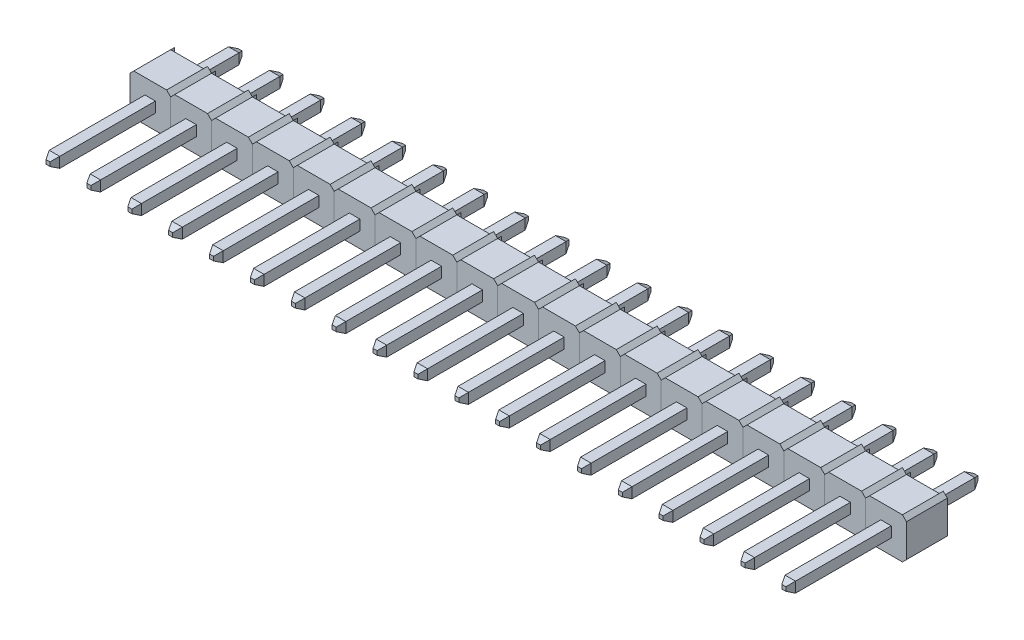
from build123d import *

# Parameters (mm, degrees)
SKETCH_14119_W             = 0.65
SKETCH_14119_H             = 0.65
EXTRUDE_14471_DEPTH        = 2.29
EXTRUDE_14851_DEPTH        = 0.25
SKETCH_14911_W             = 0.65
SKETCH_14911_H             = 0.65
EXTRUDE_15123_DEPTH        = 6.35
EXTRUDE_15123_DEPTH_BACK   = 5.59
CHAMFER_15214_SIZE         = 0.2
CHAMFER_15214_SIZE2        = 0.4
CHAMFER_15307_SIZE         = 0.2
CHAMFER_15307_SIZE2        = 0.4
PATTERN_LINEAR_15391_COUNT = 19
PATTERN_LINEAR_15391_PITCH = 2.54


with BuildPart() as part:
    # Sketch 14119 → Extrude 14471 (new body)
    with BuildSketch(Plane.XY):
        Polygon((1.02, 1.27), (1.27, 1.02), (1.27, -1.02), (1.02, -1.27), (-1.02, -1.27), (-1.27, -1.02), (-1.27, 1.02), (-1.02, 1.27), align=None)
        Rectangle(SKETCH_14119_W, SKETCH_14119_H, mode=Mode.SUBTRACT)
    extrude(amount=EXTRUDE_14471_DEPTH)

    # Sketch 14516 → Extrude 14851 (add)
    with BuildSketch(Plane(origin=(0, 0, 0), x_dir=(-1, 0, 0), z_dir=(0, 0, -1))):
        Polygon((-1.02, 1.27), (-1.27, 1.02), (-1.27, -1.02), (-1.02, -1.27), align=None)
        Polygon((1.02, 1.27), (1.27, 1.02), (1.27, -1.02), (1.02, -1.27), align=None)
    extrude(amount=EXTRUDE_14851_DEPTH)


with BuildPart() as body_2:
    # Sketch 14911 → Extrude 15123 (new body, two sides)
    with BuildSketch(Plane.XY.offset(2.29)) as extrude_15123_sk:
        Rectangle(SKETCH_14911_W, SKETCH_14911_H)
    extrude(amount=EXTRUDE_15123_DEPTH)
    extrude(extrude_15123_sk.sketch, amount=-EXTRUDE_15123_DEPTH_BACK)

    # Chamfer 15214
    chamfer_15214_edges = [body_2.edges().sort_by_distance(p)[0] for p in [
        (-0.325, 0, 8.64),
        (0, -0.325, 8.64),
        (0.325, 0, 8.64),
        (0, 0.325, 8.64),
    ]]
    chamfer_15214_side = [body_2.faces().sort_by_distance(p)[0] for p in [
        (0, 0, 8.64),
    ]]
    chamfer(chamfer_15214_edges, length=CHAMFER_15214_SIZE, length2=CHAMFER_15214_SIZE2, reference=chamfer_15214_side[0])

    # Chamfer 15307
    chamfer_15307_edges = [body_2.edges().sort_by_distance(p)[0] for p in [
        (0, -0.325, -3.3),
        (0.325, 0, -3.3),
        (0, 0.325, -3.3),
        (-0.325, 0, -3.3),
    ]]
    chamfer_15307_side = [body_2.faces().sort_by_distance(p)[0] for p in [
        (0, 0, -3.3),
    ]]
    chamfer(chamfer_15307_edges, length=CHAMFER_15307_SIZE, length2=CHAMFER_15307_SIZE2, reference=chamfer_15307_side[0])


with BuildPart() as pattern_linear_15391_1:
    # Pattern Linear 15391: pattern copy
    add(body_2.part.moved(Location(Vector(-1, 0, 0) * (1 * PATTERN_LINEAR_15391_PITCH))))


with BuildPart() as pattern_linear_15391_2:
    # Pattern Linear 15391: pattern copy
    add(body_2.part.moved(Location(Vector(-1, 0, 0) * (2 * PATTERN_LINEAR_15391_PITCH))))


with BuildPart() as pattern_linear_15391_3:
    # Pattern Linear 15391: pattern copy
    add(body_2.part.moved(Location(Vector(-1, 0, 0) * (3 * PATTERN_LINEAR_15391_PITCH))))


with BuildPart() as pattern_linear_15391_4:
    # Pattern Linear 15391: pattern copy
    add(body_2.part.moved(Location(Vector(-1, 0, 0) * (4 * PATTERN_LINEAR_15391_PITCH))))


with BuildPart() as pattern_linear_15391_5:
    # Pattern Linear 15391: pattern copy
    add(body_2.part.moved(Location(Vector(-1, 0, 0) * (5 * PATTERN_LINEAR_15391_PITCH))))


with BuildPart() as pattern_linear_15391_6:
    # Pattern Linear 15391: pattern copy
    add(body_2.part.moved(Location(Vector(-1, 0, 0) * (6 * PATTERN_LINEAR_15391_PITCH))))


with BuildPart() as pattern_linear_15391_7:
    # Pattern Linear 15391: pattern copy
    add(body_2.part.moved(Location(Vector(-1, 0, 0) * (7 * PATTERN_LINEAR_15391_PITCH))))


with BuildPart() as pattern_linear_15391_8:
    # Pattern Linear 15391: pattern copy
    add(body_2.part.moved(Location(Vector(-1, 0, 0) * (8 * PATTERN_LINEAR_15391_PITCH))))


with BuildPart() as pattern_linear_15391_9:
    # Pattern Linear 15391: pattern copy
    add(body_2.part.moved(Location(Vector(-1, 0, 0) * (9 * PATTERN_LINEAR_15391_PITCH))))


with BuildPart() as pattern_linear_15391_10:
    # Pattern Linear 15391: pattern copy
    add(body_2.part.moved(Location(Vector(-1, 0, 0) * (10 * PATTERN_LINEAR_15391_PITCH))))


with BuildPart() as pattern_linear_15391_11:
    # Pattern Linear 15391: pattern copy
    add(body_2.part.moved(Location(Vector(-1, 0, 0) * (11 * PATTERN_LINEAR_15391_PITCH))))


with BuildPart() as pattern_linear_15391_12:
    # Pattern Linear 15391: pattern copy
    add(body_2.part.moved(Location(Vector(-1, 0, 0) * (12 * PATTERN_LINEAR_15391_PITCH))))


with BuildPart() as pattern_linear_15391_13:
    # Pattern Linear 15391: pattern copy
    add(body_2.part.moved(Location(Vector(-1, 0, 0) * (13 * PATTERN_LINEAR_15391_PITCH))))


with BuildPart() as pattern_linear_15391_14:
    # Pattern Linear 15391: pattern copy
    add(body_2.part.moved(Location(Vector(-1, 0, 0) * (14 * PATTERN_LINEAR_15391_PITCH))))


with BuildPart() as pattern_linear_15391_15:
    # Pattern Linear 15391: pattern copy
    add(body_2.part.moved(Location(Vector(-1, 0, 0) * (15 * PATTERN_LINEAR_15391_PITCH))))


with BuildPart() as pattern_linear_15391_16:
    # Pattern Linear 15391: pattern copy
    add(body_2.part.moved(Location(Vector(-1, 0, 0) * (16 * PATTERN_LINEAR_15391_PITCH))))


with BuildPart() as pattern_linear_15391_17:
    # Pattern Linear 15391: pattern copy
    add(body_2.part.moved(Location(Vector(-1, 0, 0) * (17 * PATTERN_LINEAR_15391_PITCH))))


with BuildPart() as pattern_linear_15391_18:
    # Pattern Linear 15391: pattern copy
    add(body_2.part.moved(Location(Vector(-1, 0, 0) * (18 * PATTERN_LINEAR_15391_PITCH))))


with BuildPart() as pattern_linear_15391_19:
    # Pattern Linear 15391: pattern copy
    add(part.part.moved(Location(Vector(-1, 0, 0) * (1 * PATTERN_LINEAR_15391_PITCH))))


with BuildPart() as pattern_linear_15391_20:
    # Pattern Linear 15391: pattern copy
    add(part.part.moved(Location(Vector(-1, 0, 0) * (2 * PATTERN_LINEAR_15391_PITCH))))


with BuildPart() as pattern_linear_15391_21:
    # Pattern Linear 15391: pattern copy
    add(part.part.moved(Location(Vector(-1, 0, 0) * (3 * PATTERN_LINEAR_15391_PITCH))))


with BuildPart() as pattern_linear_15391_22:
    # Pattern Linear 15391: pattern copy
    add(part.part.moved(Location(Vector(-1, 0, 0) * (4 * PATTERN_LINEAR_15391_PITCH))))


with BuildPart() as pattern_linear_15391_23:
    # Pattern Linear 15391: pattern copy
    add(part.part.moved(Location(Vector(-1, 0, 0) * (5 * PATTERN_LINEAR_15391_PITCH))))


with BuildPart() as pattern_linear_15391_24:
    # Pattern Linear 15391: pattern copy
    add(part.part.moved(Location(Vector(-1, 0, 0) * (6 * PATTERN_LINEAR_15391_PITCH))))


with BuildPart() as pattern_linear_15391_25:
    # Pattern Linear 15391: pattern copy
    add(part.part.moved(Location(Vector(-1, 0, 0) * (7 * PATTERN_LINEAR_15391_PITCH))))


with BuildPart() as pattern_linear_15391_26:
    # Pattern Linear 15391: pattern copy
    add(part.part.moved(Location(Vector(-1, 0, 0) * (8 * PATTERN_LINEAR_15391_PITCH))))


with BuildPart() as pattern_linear_15391_27:
    # Pattern Linear 15391: pattern copy
    add(part.part.moved(Location(Vector(-1, 0, 0) * (9 * PATTERN_LINEAR_15391_PITCH))))


with BuildPart() as pattern_linear_15391_28:
    # Pattern Linear 15391: pattern copy
    add(part.part.moved(Location(Vector(-1, 0, 0) * (10 * PATTERN_LINEAR_15391_PITCH))))


with BuildPart() as pattern_linear_15391_29:
    # Pattern Linear 15391: pattern copy
    add(part.part.moved(Location(Vector(-1, 0, 0) * (11 * PATTERN_LINEAR_15391_PITCH))))


with BuildPart() as pattern_linear_15391_30:
    # Pattern Linear 15391: pattern copy
    add(part.part.moved(Location(Vector(-1, 0, 0) * (12 * PATTERN_LINEAR_15391_PITCH))))


with BuildPart() as pattern_linear_15391_31:
    # Pattern Linear 15391: pattern copy
    add(part.part.moved(Location(Vector(-1, 0, 0) * (13 * PATTERN_LINEAR_15391_PITCH))))


with BuildPart() as pattern_linear_15391_32:
    # Pattern Linear 15391: pattern copy
    add(part.part.moved(Location(Vector(-1, 0, 0) * (14 * PATTERN_LINEAR_15391_PITCH))))


with BuildPart() as pattern_linear_15391_33:
    # Pattern Linear 15391: pattern copy
    add(part.part.moved(Location(Vector(-1, 0, 0) * (15 * PATTERN_LINEAR_15391_PITCH))))


with BuildPart() as pattern_linear_15391_34:
    # Pattern Linear 15391: pattern copy
    add(part.part.moved(Location(Vector(-1, 0, 0) * (16 * PATTERN_LINEAR_15391_PITCH))))


with BuildPart() as pattern_linear_15391_35:
    # Pattern Linear 15391: pattern copy
    add(part.part.moved(Location(Vector(-1, 0, 0) * (17 * PATTERN_LINEAR_15391_PITCH))))


with BuildPart() as pattern_linear_15391_36:
    # Pattern Linear 15391: pattern copy
    add(part.part.moved(Location(Vector(-1, 0, 0) * (18 * PATTERN_LINEAR_15391_PITCH))))


solid = Compound([part.part, body_2.part, pattern_linear_15391_1.part, pattern_linear_15391_2.part, pattern_linear_15391_3.part, pattern_linear_15391_4.part, pattern_linear_15391_5.part, pattern_linear_15391_6.part, pattern_linear_15391_7.part, pattern_linear_15391_8.part, pattern_linear_15391_9.part, pattern_linear_15391_10.part, pattern_linear_15391_11.part, pattern_linear_15391_12.part, pattern_linear_15391_13.part, pattern_linear_15391_14.part, pattern_linear_15391_15.part, pattern_linear_15391_16.part, pattern_linear_15391_17.part, pattern_linear_15391_18.part, pattern_linear_15391_19.part, pattern_linear_15391_20.part, pattern_linear_15391_21.part, pattern_linear_15391_22.part, pattern_linear_15391_23.part, pattern_linear_15391_24.part, pattern_linear_15391_25.part, pattern_linear_15391_26.part, pattern_linear_15391_27.part, pattern_linear_15391_28.part, pattern_linear_15391_29.part, pattern_linear_15391_30.part, pattern_linear_15391_31.part, pattern_linear_15391_32.part, pattern_linear_15391_33.part, pattern_linear_15391_34.part, pattern_linear_15391_35.part, pattern_linear_15391_36.part])
